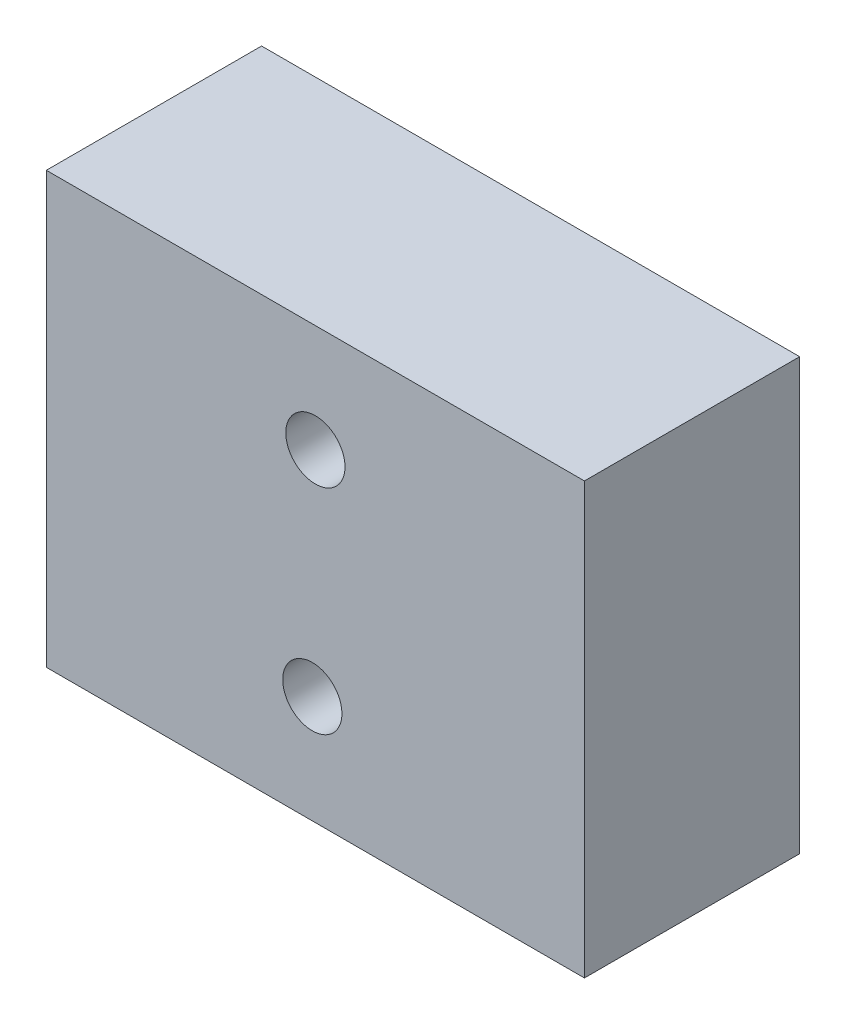
from build123d import *

# Parameters (mm, degrees)
SKETCH1_W                             = 50
SKETCH1_H                             = 20
BOSS_EXTRUDE1_DEPTH                   = 40
M5_CLEARANCE_HOLE1_D                  = 5.5
F_97_0_0059_DIAMETER_HOLE1_AT_2_COUNT = 2
F_97_0_0059_DIAMETER_HOLE1_AT_2_PITCH = 31


with BuildPart() as part:
    # Sketch1 → Boss-Extrude1 (new body)
    with BuildSketch(Plane(origin=(0, 0, 0), x_dir=(1, 0, 0), z_dir=(0, 1, 0))):
        with Locations((25, 10)):
            Rectangle(SKETCH1_W, SKETCH1_H)
    extrude(amount=BOSS_EXTRUDE1_DEPTH)

    # M5 Clearance Hole1 (through all)
    with Locations(Plane.XY):
        with Locations((25, 30), (24.715809074, 10)):
            Hole(M5_CLEARANCE_HOLE1_D / 2)

    # Sketch6 → #97 (0.0059) Diameter Hole1 (revolve, cut)
    with BuildSketch(Plane(origin=(40, 0, -10), x_dir=(0, 0, -1), z_dir=(1, 0, 0))):
        Polygon((0, 0), (0, 14.304540818), (3.8354, 12), (3.8354, 0.71572306), (3.8603936, 0), align=None)
    f_97_0_0059_diameter_hole1 = revolve(axis=Axis((40, -6.35, -10), (0, 1, 0)), mode=Mode.SUBTRACT)

    # #97 (0.0059) Diameter Hole1 at 2: #97 (0.0059) Diameter Hole1 ×2
    with Locations(*[(-i * F_97_0_0059_DIAMETER_HOLE1_AT_2_PITCH, 0, 0) for i in range(1, F_97_0_0059_DIAMETER_HOLE1_AT_2_COUNT)]):
        add(f_97_0_0059_diameter_hole1, mode=Mode.SUBTRACT)


solid = part.part
